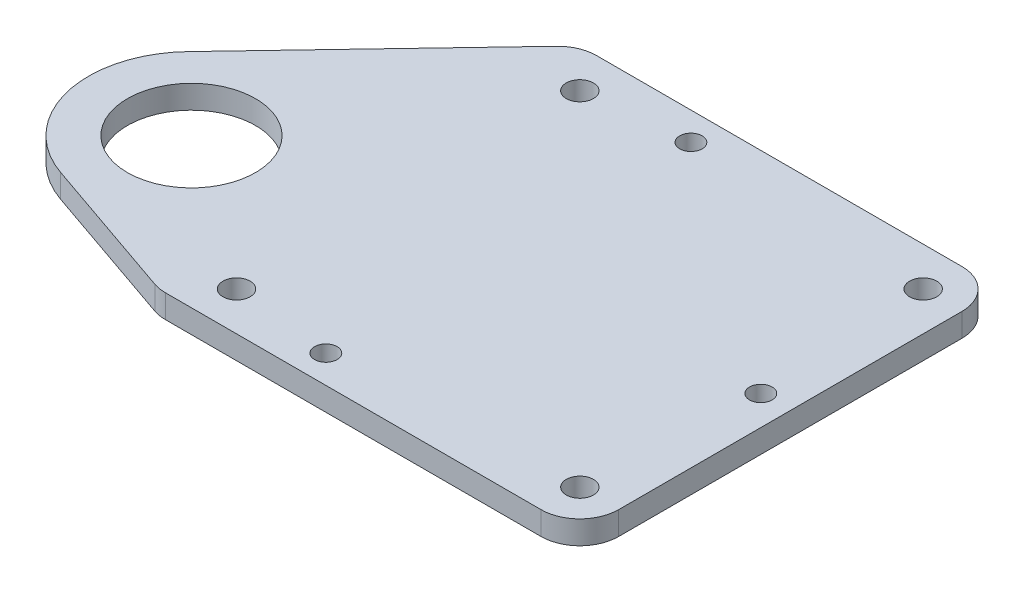
from build123d import *

# Parameters (mm, degrees)
SKETCH1_R           = 1.75
SKETCH1_R_2         = 1.45
SKETCH1_R_3         = 8.25
BOSS_EXTRUDE1_DEPTH = 3
FILLET1_R           = 5


with BuildPart() as part:
    # Sketch1 → Boss-Extrude1 (new body)
    with BuildSketch(Plane(origin=(0, 0, 0), x_dir=(1, 0, 0), z_dir=(0, 1, 0))):
        with BuildLine():
            Line((54.2, 54.2), (0, 54.2))
            Line((0, 54.2), (-24.601445865, 28.330976799))
            ThreePointArc((-24.601445865, 28.330976799), (-27.87353462, 16.063982402), (-19.326300343, 6.676197648))
            Line((-19.326300343, 6.676197648), (0, 0))
            Line((0, 0), (54.2, 0))
            Line((54.2, 0), (54.2, 54.2))
        make_face()
        with Locations((5, 5)):
            Circle(SKETCH1_R, mode=Mode.SUBTRACT)
        with Locations((17.9, 3.6)):
            Circle(SKETCH1_R_2, mode=Mode.SUBTRACT)
        with Locations((49.2, 5)):
            Circle(SKETCH1_R, mode=Mode.SUBTRACT)
        with Locations((5, 49.2)):
            Circle(SKETCH1_R, mode=Mode.SUBTRACT)
        with Locations((50.4, 27.1)):
            Circle(SKETCH1_R_2, mode=Mode.SUBTRACT)
        with Locations((17.9, 50.6)):
            Circle(SKETCH1_R_2, mode=Mode.SUBTRACT)
        with Locations((49.2, 49.2)):
            Circle(SKETCH1_R, mode=Mode.SUBTRACT)
        with Locations((-15, 19.2)):
            Circle(SKETCH1_R_3, mode=Mode.SUBTRACT)
    extrude(amount=BOSS_EXTRUDE1_DEPTH)

    # Fillet1
    fillet1_edges = [part.edges().sort_by_distance(p)[0] for p in [
        (0, 1.5, 0),
        (0, 1.5, -54.2),
        (54.2, 1.5, -54.2),
        (54.2, 1.5, 0),
    ]]
    fillet(fillet1_edges, radius=FILLET1_R)


solid = part.part
